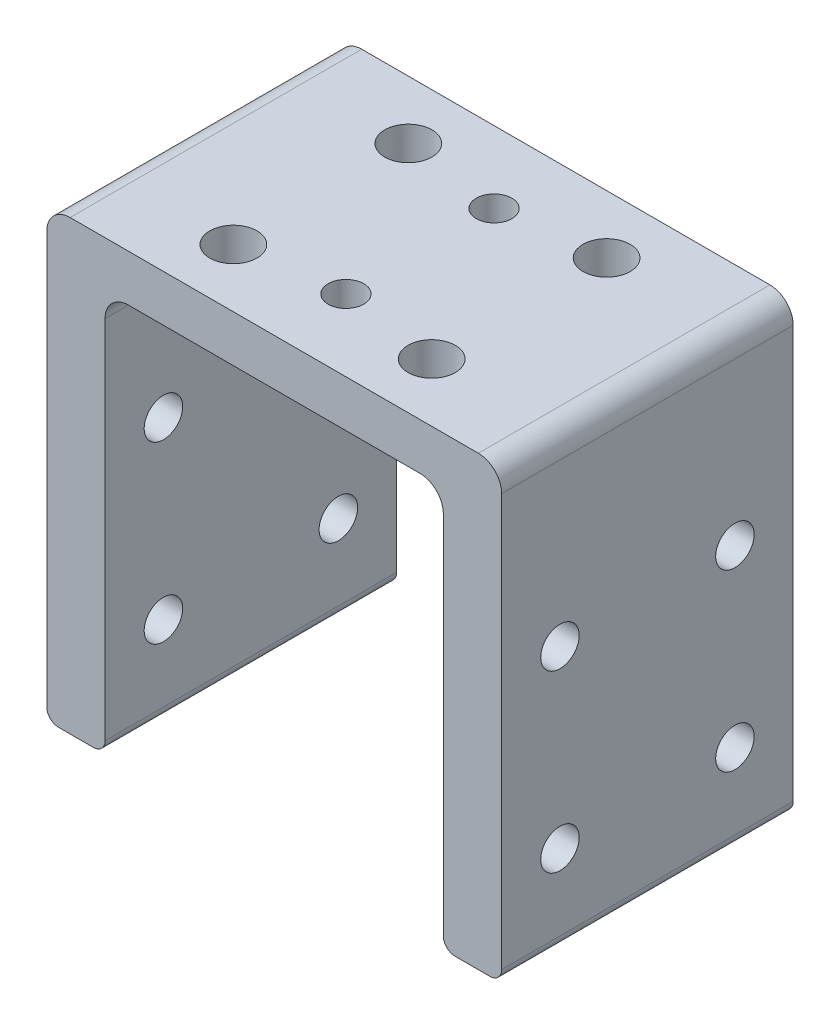
from build123d import *

# Parameters (mm, degrees)
SKETCH_1_W               = 39
SKETCH_1_H               = 49
EXTRUDE_1_DEPTH          = 25
SKETCH_3_W               = 29
SKETCH_3_H               = 45
CUT_EXTRUDE_1_DEPTH      = 25
SKETCH_5_W               = 39
SKETCH_5_H               = 5
CUT_EXTRUDE_3_DEPTH      = 1
CUT_EXTRUDE_3_DEPTH_BACK = 26
HOLE_WIZARD_M4_4_D       = 3.3
SKETCH_20_W              = 39
SKETCH_20_H              = 5.65
CUT_EXTRUDE_5_DEPTH      = 1
CUT_EXTRUDE_5_DEPTH_BACK = 26
SKETCH_7_R               = 2.025
CUT_EXTRUDE_7_DEPTH      = 10
FILLET_1_R               = 2
FILLET_2_R               = 1
SKETCH_21_R              = 1.525
CUT_EXTRUDE_8_DEPTH      = 10


with BuildPart() as part:
    # 草图1 → 凸台-拉伸1 (new body)
    with BuildSketch(Plane.XY):
        Rectangle(SKETCH_1_W, SKETCH_1_H)
    extrude(amount=EXTRUDE_1_DEPTH)

    # 草图3 → 切除-拉伸1 (cut)
    with BuildSketch(Plane.XY.offset(25)):
        with Locations((0, -2)):
            Rectangle(SKETCH_3_W, SKETCH_3_H)
    extrude(amount=-CUT_EXTRUDE_1_DEPTH, mode=Mode.SUBTRACT)

    # 草图5 → 切除-拉伸3 (cut, two sides)
    with BuildSketch(Plane.XY.offset(25)) as cut_extrude_3_sk:
        with Locations((0, -22)):
            Rectangle(SKETCH_5_W, SKETCH_5_H)
    extrude(amount=CUT_EXTRUDE_3_DEPTH, mode=Mode.SUBTRACT)
    extrude(cut_extrude_3_sk.sketch, amount=-CUT_EXTRUDE_3_DEPTH_BACK, mode=Mode.SUBTRACT)

    # M4 螺纹孔4 (through all)
    with Locations(Plane(origin=(-19.5, 8.65, 5), x_dir=(0, 0, -1), z_dir=(-1, 0, 0))):
        with Locations((0, 0), (-15, 0), (-15, 15), (0, 15)):
            Hole(HOLE_WIZARD_M4_4_D / 2)

    # 草图20 → 切除-拉伸5 (cut, two sides)
    with BuildSketch(Plane.XY.offset(25)) as cut_extrude_5_sk:
        with Locations((0, -16.675)):
            Rectangle(SKETCH_20_W, SKETCH_20_H)
    extrude(amount=CUT_EXTRUDE_5_DEPTH, mode=Mode.SUBTRACT)
    extrude(cut_extrude_5_sk.sketch, amount=-CUT_EXTRUDE_5_DEPTH_BACK, mode=Mode.SUBTRACT)

    # 草图7 → 切除-拉伸7 (cut)
    with BuildSketch(Plane.XZ.offset(-20.5)):
        with Locations((-8.5, 20)):
            Circle(SKETCH_7_R)
        with Locations((-8.5, 5)):
            Circle(SKETCH_7_R)
        with Locations((8.5, 5)):
            Circle(SKETCH_7_R)
        with Locations((8.5, 20)):
            Circle(SKETCH_7_R)
    extrude(amount=-CUT_EXTRUDE_7_DEPTH, mode=Mode.SUBTRACT)

    # 圆角1
    fillet_1_edges = [part.edges().sort_by_distance(p)[0] for p in [
        (-14.5, 20.5, 12.5),
        (14.5, 20.5, 12.5),
        (-19.5, 24.5, 12.5),
        (19.5, 24.5, 12.5),
    ]]
    fillet(fillet_1_edges, radius=FILLET_1_R)

    # 圆角2
    fillet_2_edges = [part.edges().sort_by_distance(p)[0] for p in [
        (14.5, -13.85, 12.5),
        (-14.5, -13.85, 12.5),
        (-19.5, -13.85, 12.5),
        (19.5, -13.85, 12.5),
    ]]
    fillet(fillet_2_edges, radius=FILLET_2_R)

    # 草图21 → 切除-拉伸8 (cut)
    with BuildSketch(Plane(origin=(0, 24.5, 0), x_dir=(1, 0, 0), z_dir=(0, 1, 0))):
        with Locations((0, -6.15)):
            Circle(SKETCH_21_R)
        with Locations((0, -18.85)):
            Circle(SKETCH_21_R)
    extrude(amount=-CUT_EXTRUDE_8_DEPTH, mode=Mode.SUBTRACT)


solid = part.part
